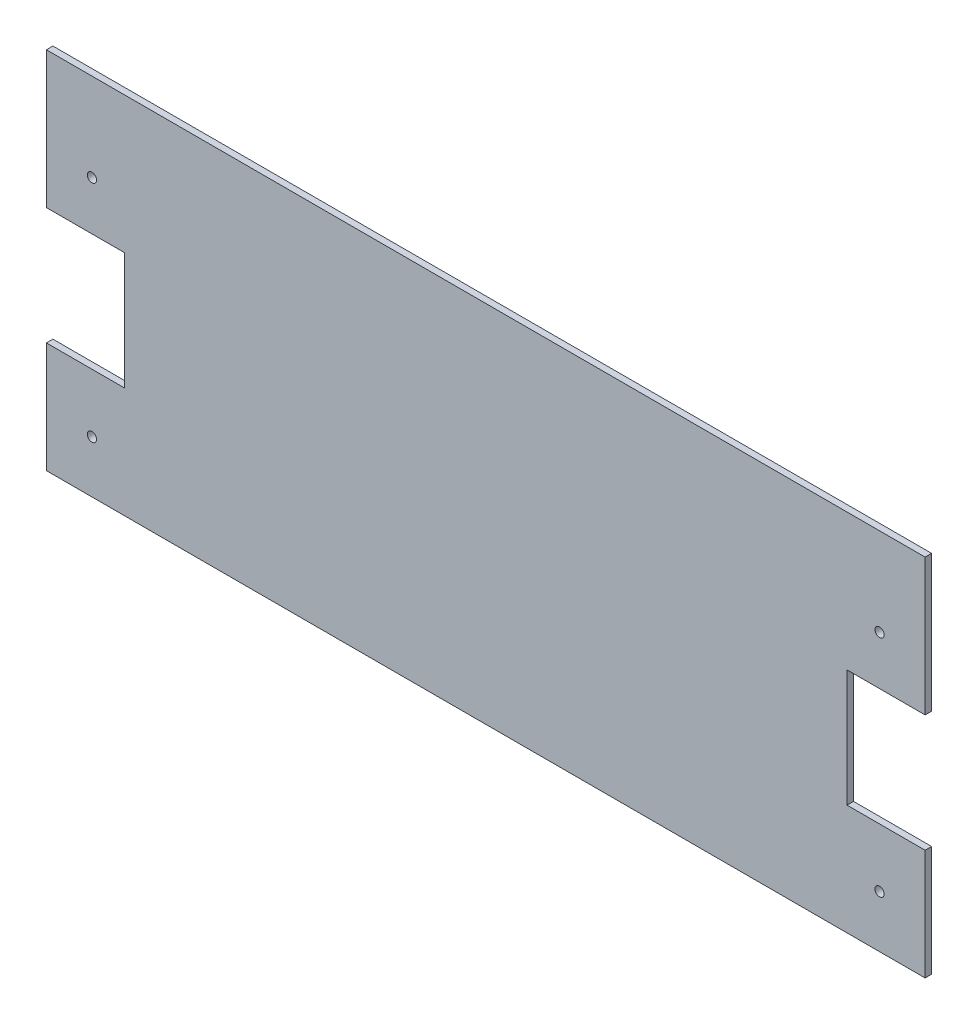
from build123d import *

# Parameters (mm, degrees)
SKETCH1_R           = 2.25
BOSS_EXTRUDE1_DEPTH = 3.175


with BuildPart() as part:
    # Sketch1 → Boss-Extrude1 (new body)
    with BuildSketch(Plane.XY):
        Polygon((-214.3125, -34.925), (-214.3125, -88.9), (214.3125, -88.9), (214.3125, -34.925), (176.2125, -34.925), (176.2125, 22.225), (214.3125, 22.225), (214.3125, 88.9), (-214.3125, 88.9), (-214.3125, 22.225), (-176.2125, 22.225), (-176.2125, -34.925), align=None)
        with Locations((-192.0875, -63.5)):
            Circle(SKETCH1_R, mode=Mode.SUBTRACT)
        with Locations((192.0875, -63.5)):
            Circle(SKETCH1_R, mode=Mode.SUBTRACT)
        with Locations((-192.0875, 46.0375)):
            Circle(SKETCH1_R, mode=Mode.SUBTRACT)
        with Locations((192.0875, 46.0375)):
            Circle(SKETCH1_R, mode=Mode.SUBTRACT)
    extrude(amount=-BOSS_EXTRUDE1_DEPTH)


solid = part.part
